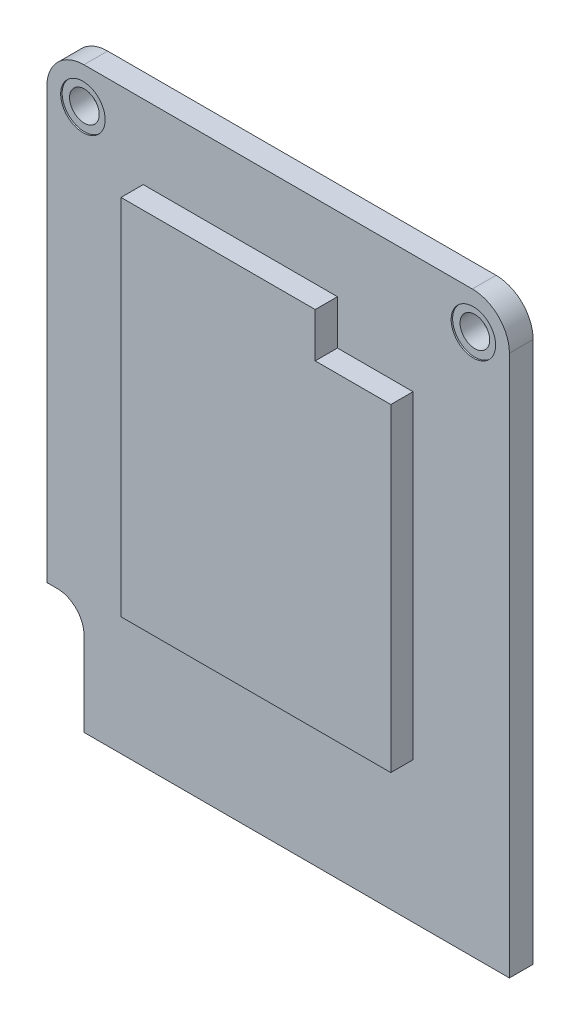
from build123d import *

# Parameters (mm, degrees)
SKETCH1_R           = 1.5
BOSS_EXTRUDE1_DEPTH = 1.6
BOSS_EXTRUDE2_START = 0.1
SKETCH1_5_R         = 1.5
SKETCH1_5_R_2       = 1
BOSS_EXTRUDE2_DEPTH = 1.4
BOSS_EXTRUDE3_DEPTH = 1.5


with BuildPart() as part:
    # Sketch1 → Boss-Extrude1 (new body)
    with BuildSketch(Plane.XY):
        with BuildLine():
            Line((-15.6, 17), (-15.6, -12))
            Line((-15.6, -12), (-14.9, -12))
            ThreePointArc((-14.9, -12), (-13.627207794, -12.527207794), (-13.1, -13.8))
            Line((-13.1, -13.8), (-13.1, -19.5))
            Line((-13.1, -19.5), (15.6, -19.5))
            Line((15.6, -19.5), (15.6, 17))
            ThreePointArc((15.6, 17), (14.867766953, 18.767766953), (13.1, 19.5))
            Line((13.1, 19.5), (-13.1, 19.5))
            ThreePointArc((-13.1, 19.5), (-14.867766953, 18.767766953), (-15.6, 17))
        make_face()
        with Locations((-13.17, 17)):
            Circle(SKETCH1_R, mode=Mode.SUBTRACT)
        with Locations((13.17, 17)):
            Circle(SKETCH1_R, mode=Mode.SUBTRACT)
    extrude(amount=BOSS_EXTRUDE1_DEPTH)

    # Sketch1_5 → Boss-Extrude2 (add)
    with BuildSketch(Plane.XY.offset(BOSS_EXTRUDE2_START)):
        with Locations((13.17, 17)):
            Circle(SKETCH1_5_R)
        with Locations((13.17, 17)):
            Circle(SKETCH1_5_R_2, mode=Mode.SUBTRACT)
        with Locations((-13.17, 17)):
            Circle(SKETCH1_5_R)
        with Locations((-13.17, 17)):
            Circle(SKETCH1_5_R_2, mode=Mode.SUBTRACT)
    extrude(amount=BOSS_EXTRUDE2_DEPTH)

    # Sketch2 → Boss-Extrude3 (add)
    with BuildSketch(Plane.XY.offset(1.6)):
        Polygon((-9.1, 14.5), (4, 14.5), (4, 11.5), (9.1, 11.5), (9.1, -10), (-9.1, -10), align=None)
    extrude(amount=BOSS_EXTRUDE3_DEPTH)


solid = part.part
